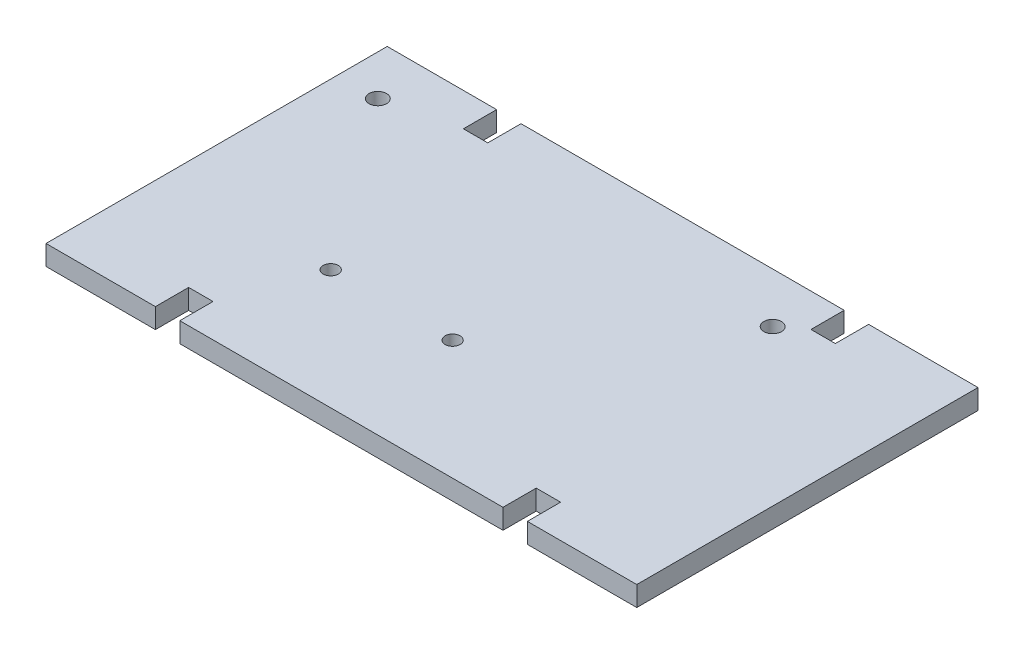
from build123d import *

# Parameters (mm, degrees)
SKETCH1_W              = 135.382
SKETCH1_H              = 62.96
SKETCH1_W_2            = 25.0698
SKETCH1_H_2            = 7.62
SKETCH1_W_3            = 74.0664
BOSS_EXTRUDE1_DEPTH    = 4.572
F_10_32_TAPPED_HOLE1_D = 4.0386
F_8_32_TAPPED_HOLE1_D  = 3.4544


with BuildPart() as part:
    # Sketch1 → Boss-Extrude1 (new body)
    with BuildSketch(Plane(origin=(0, 0, 0), x_dir=(1, 0, 0), z_dir=(0, 1, 0))):
        Rectangle(SKETCH1_W, SKETCH1_H)
        with Locations((55.1561, 35.29)):
            Rectangle(SKETCH1_W_2, SKETCH1_H_2)
        with Locations((0, 35.29)):
            Rectangle(SKETCH1_W_3, SKETCH1_H_2)
        with Locations((-55.1561, 35.29)):
            Rectangle(SKETCH1_W_2, SKETCH1_H_2)
        with Locations((-55.1561, -35.29)):
            Rectangle(SKETCH1_W_2, SKETCH1_H_2)
        with Locations((0, -35.29)):
            Rectangle(SKETCH1_W_3, SKETCH1_H_2)
        with Locations((55.1561, -35.29)):
            Rectangle(SKETCH1_W_2, SKETCH1_H_2)
    extrude(amount=BOSS_EXTRUDE1_DEPTH)

    # #10-32 Tapped Hole1 (through all)
    with Locations(Plane(origin=(0, 4.572, 0), x_dir=(1, 0, 0), z_dir=(0, 1, 0))):
        with Locations((-58.42, 27.67), (32.0675, 27.67)):
            Hole(F_10_32_TAPPED_HOLE1_D / 2)

    # #8-32 Tapped Hole1 (through all)
    with Locations(Plane(origin=(0, 4.572, 0), x_dir=(1, 0, 0), z_dir=(0, 1, 0))):
        with Locations((-29.845, -11.7), (-1.905, -11.7)):
            Hole(F_8_32_TAPPED_HOLE1_D / 2)


solid = part.part
